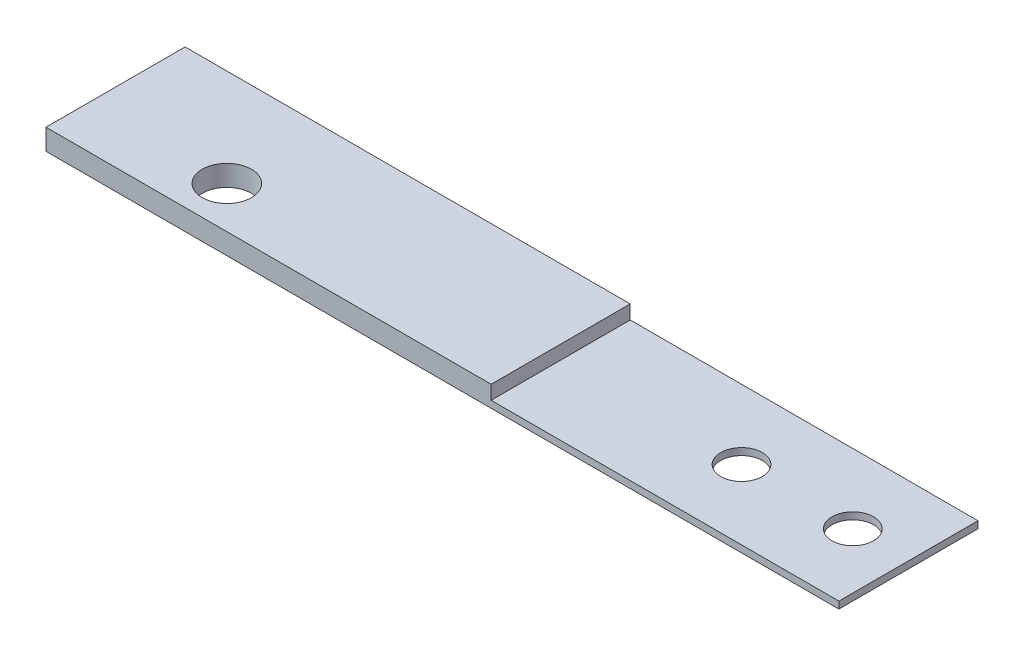
from build123d import *

# Parameters (mm, degrees)
SKETCH1_W               = 72.39
SKETCH1_H               = 12.7
BOSS_EXTRUDE1_DEPTH     = 0.635
SKETCH2_W               = 40.64
SKETCH2_H               = 12.7
BOSS_EXTRUDE2_DEPTH     = 1.27
F_6_CLEARANCE_HOLE1_D   = 3.7973
F_8_CLEARANCE_HOLE1_D   = 4.4958
CUT_EXTRUDE6_DEPTH      = 1
CUT_EXTRUDE6_DEPTH_BACK = 10.16


with BuildPart() as part:
    # Sketch1 → Boss-Extrude1 (new body)
    with BuildSketch(Plane(origin=(0, 0, 0), x_dir=(1, 0, 0), z_dir=(0, 1, 0))):
        with Locations((36.195, -6.35)):
            Rectangle(SKETCH1_W, SKETCH1_H)
    extrude(amount=BOSS_EXTRUDE1_DEPTH)

    # Sketch2 → Boss-Extrude2 (add)
    with BuildSketch(Plane(origin=(0, 0.635, 0), x_dir=(1, 0, 0), z_dir=(0, 1, 0))):
        with Locations((20.32, -6.35)):
            Rectangle(SKETCH2_W, SKETCH2_H)
    extrude(amount=BOSS_EXTRUDE2_DEPTH)

    # #6 Clearance Hole1 (through all)
    with Locations(Plane(origin=(0, 0, 0), x_dir=(-1, 0, 0), z_dir=(0, -1, 0))):
        with Locations((-67.31, -6.35), (-57.15, -6.35)):
            Hole(F_6_CLEARANCE_HOLE1_D / 2)

    # #8 Clearance Hole1 (through all)
    with Locations(Plane(origin=(0, 0, 0), x_dir=(-1, 0, 0), z_dir=(0, -1, 0))):
        with Locations((-12.7, -8.89)):
            Hole(F_8_CLEARANCE_HOLE1_D / 2)

    # Sketch9 → Cut-Extrude6 (cut, two sides)
    with BuildSketch(Plane.ZY) as cut_extrude6_sk:
        Polygon((1.563293937, 0.508), (1.27, 0), (1.856587873, 0), align=None)
        Polygon((2.14988181, 0.508), (1.856587873, 0), (2.443175747, 0), align=None)
        Polygon((0.87988181, 0.508), (0.586587873, 0), (1.173175747, 0), align=None)
        Polygon((0.293293937, 0.508), (0, 0), (0.586587873, 0), align=None)
        Polygon((2.833293937, 0.508), (2.54, 0), (3.126587873, 0), align=None)
        Polygon((3.41988181, 0.508), (3.126587873, 0), (3.713175747, 0), align=None)
        Polygon((4.103293937, 0.508), (3.81, 0), (4.396587873, 0), align=None)
        Polygon((4.68988181, 0.508), (4.396587873, 0), (4.983175747, 0), align=None)
        Polygon((5.373293937, 0.508), (5.08, 0), (5.666587873, 0), align=None)
        Polygon((5.95988181, 0.508), (5.666587873, 0), (6.253175747, 0), align=None)
        Polygon((6.643293937, 0.508), (6.35, 0), (6.936587873, 0), align=None)
        Polygon((7.22988181, 0.508), (6.936587873, 0), (7.523175747, 0), align=None)
        Polygon((7.913293937, 0.508), (7.62, 0), (8.206587873, 0), align=None)
        Polygon((8.49988181, 0.508), (8.206587873, 0), (8.793175747, 0), align=None)
        Polygon((9.183293937, 0.508), (8.89, 0), (9.476587873, 0), align=None)
        Polygon((9.76988181, 0.508), (9.476587873, 0), (10.063175747, 0), align=None)
        Polygon((10.453293937, 0.508), (10.16, 0), (10.746587873, 0), align=None)
        Polygon((11.03988181, 0.508), (10.746587873, 0), (11.333175747, 0), align=None)
        Polygon((11.723293937, 0.508), (11.43, 0), (12.016587873, 0), align=None)
        Polygon((12.30988181, 0.508), (12.016587873, 0), (12.603175747, 0), align=None)
    extrude(amount=CUT_EXTRUDE6_DEPTH, mode=Mode.SUBTRACT)
    extrude(cut_extrude6_sk.sketch, amount=-CUT_EXTRUDE6_DEPTH_BACK, mode=Mode.SUBTRACT)


solid = part.part
